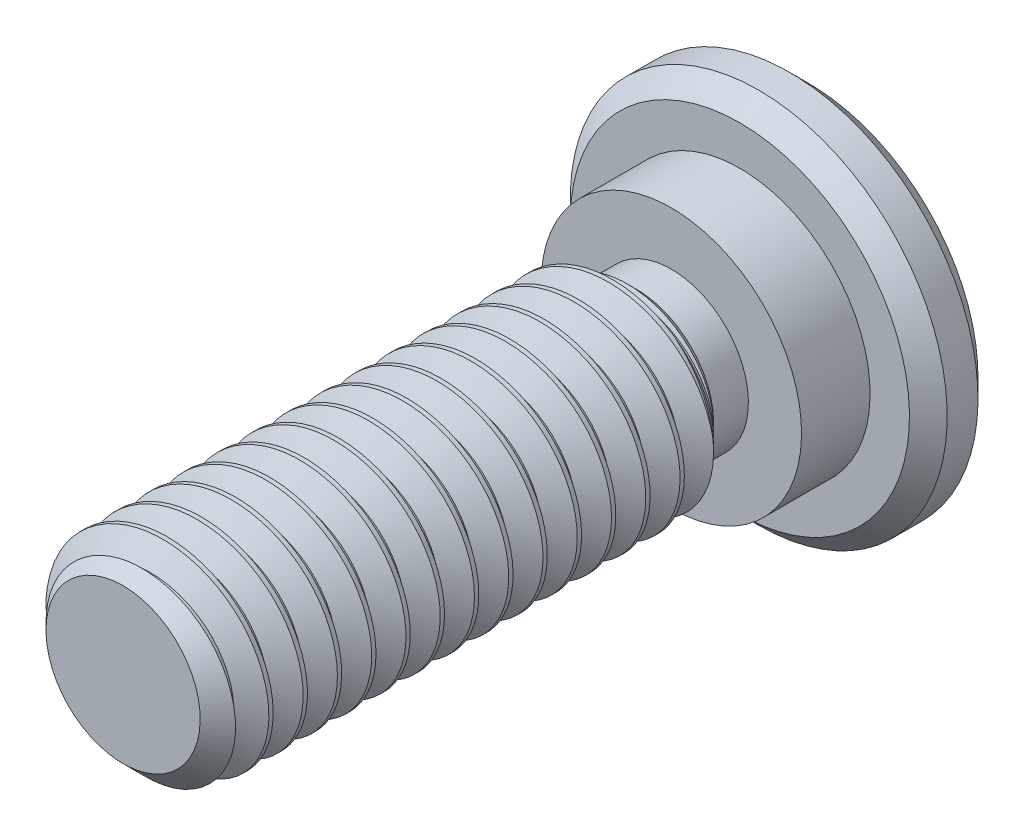
from build123d import *

# Parameters (mm, degrees)
CHAMFER2_SIZE          = 0.375
CUT_EXTRUDE1_DEPTH     = 1.5
CHAMFER1_SIZE          = 0.275
CUT_SWEEP1_PITCH       = 0.5
CUT_SWEEP1_HEIGHT      = 7.9
CUT_SWEEP1_RADIUS      = 1.5
CUT_SWEEP1_START_ANGLE = 90


with BuildPart() as part:
    # Sketch13 → Revolve1 (revolve)
    with BuildSketch(Plane(origin=(0, 0, 0), x_dir=(0, 0, -1), z_dir=(1, 0, 0)), mode=Mode.PRIVATE) as revolve1_sk:
        Polygon((1, 2.75), (0, 2.75), (0, 1.9), (-1, 1.9), (-1, 1.125), (-1.508, 1.125), (-1.883, 1.5), (-9, 1.5), (-9, 0), (1, 0), align=None)
    revolve(revolve1_sk.sketch.rotate(Axis((0, 0, 9), (0, 0, -1)), 180), axis=Axis((0, 0, 9), (0, 0, -1)))

    # Chamfer2
    chamfer2_edges = [part.edges().sort_by_distance(p)[0] for p in [
        (0, 1.5, 9),
    ]]
    chamfer(chamfer2_edges, length=CHAMFER2_SIZE)

    # Sketch7 → Cut-Extrude1 (cut)
    with BuildSketch(Plane(origin=(0, 0, -1), x_dir=(-1, 0, 0), z_dir=(0, 0, -1))):
        Polygon((0, 1.154700538), (-1, 0.577350269), (-1, -0.577350269), (0, -1.154700538), (1, -0.577350269), (1, 0.577350269), align=None)
    extrude(amount=-CUT_EXTRUDE1_DEPTH, mode=Mode.SUBTRACT)

    # Chamfer1
    chamfer1_edges = [part.edges().sort_by_distance(p)[0] for p in [
        (0, 2.75, 0),
        (0, 2.75, -1),
    ]]
    chamfer(chamfer1_edges, length=CHAMFER1_SIZE)

    # Cut-Extrude2 cone 1 section (through the dimple's axis) → Cut-Extrude2 (revolve, cut)
    with BuildSketch(Plane(origin=(0, 0, -1), x_dir=(0, 1, 0), z_dir=(1, 0, 0))):
        Polygon((0, 0), (1.154700538, 0), (0, 1.154700538), align=None)
    revolve(axis=Axis((0, 0, -1), (0, 0, 1)), mode=Mode.SUBTRACT)

    # Cut-Sweep1: sweep along a helix
    with BuildLine() as cut_sweep1_path:
        add(Helix(CUT_SWEEP1_PITCH, CUT_SWEEP1_HEIGHT, CUT_SWEEP1_RADIUS, center=(0, 0, 9), direction=(0, 0, -1), mode=Mode.PRIVATE).rotate(Axis((0, 0, 9), (0, 0, -1)), CUT_SWEEP1_START_ANGLE))
    # Sketch3 → Cut-Sweep1 (sweep, cut)
    with BuildSketch(Plane(origin=(0, 0, 0), x_dir=(0, 0, -1), z_dir=(1, 0, 0))):
        Polygon((-9.453125, 1.527063294), (-8.984375, 1.527063294), (-9.1875, 1.175240474), (-9.25, 1.175240474), align=None)
    sweep(path=cut_sweep1_path.line, is_frenet=True, mode=Mode.SUBTRACT)


solid = part.part
